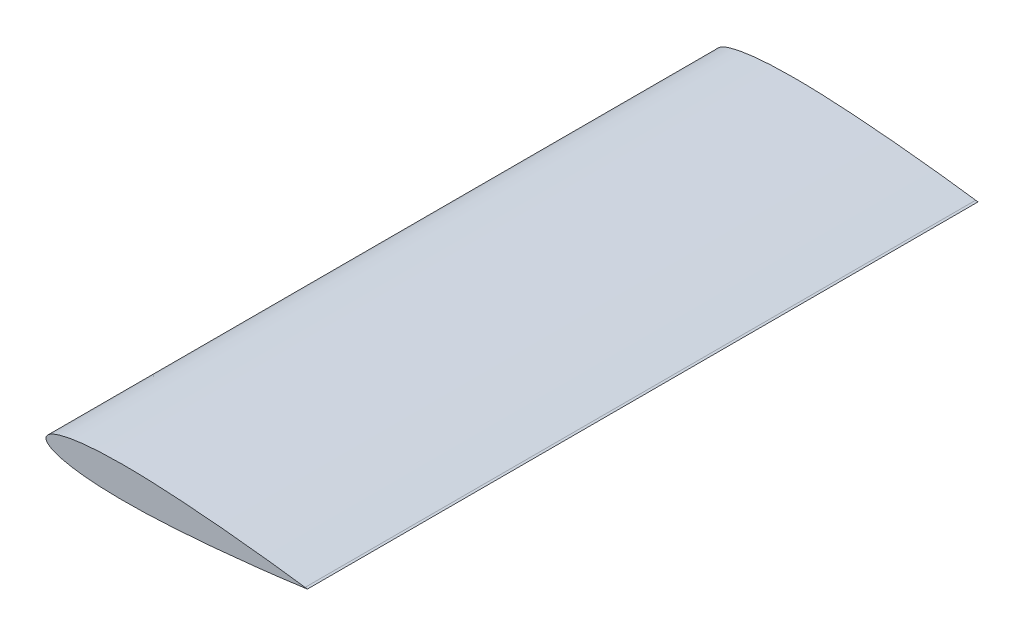
from build123d import *

# Parameters (mm, degrees)
BOSS_EXTRUDE1_DEPTH = 220


with BuildPart() as part:
    # Sketch1 → Boss-Extrude1 (new body, symmetric)
    with BuildSketch(Plane.XY):
        with BuildLine():
            Line((170, 0.2142), (171.526860264, 0))
            Line((171.526860264, 0), (170, -0.2142))
            add(Edge.make_bspline(
                [(170, 0.2142), (169.966912443, 0.218841783), (169.834644693, 0.237397347), (169.537331795, 0.279020665), (169.042585832, 0.348135674), (168.351558182, 0.444216313), (167.465863607, 0.566673358), (166.387572959, 0.714703343), (165.119198798, 0.887388895), (163.663704997, 1.083620123), (162.024491695, 1.302240346), (160.205384018, 1.541874109), (158.210635248, 1.801234189), (156.044891082, 2.078726966), (153.713220647, 2.372929467), (151.221064664, 2.68219487), (148.574250468, 3.004964361), (145.778948667, 3.339545929), (142.841695728, 3.68429103), (139.769352063, 4.037505882), (136.569099282, 4.397547939), (133.248399008, 4.762587708), (128.603273013, 5.261008627), (123.823466764, 5.75403377), (118.920129266, 6.238359408), (115.118534428, 6.602078324), (111.246602437, 6.959989686), (107.31336672, 7.310084978), (103.328024817, 7.650351054), (99.299869798, 7.978725616), (95.238315945, 8.293063594), (91.152846311, 8.591261597), (87.053003855, 8.871084403), (82.948358769, 9.130334997), (78.848496902, 9.366808942), (74.762991866, 9.57830934), (70.701378826, 9.762705464), (66.673140242, 9.917904381), (62.687685268, 10.041909396), (58.75432258, 10.132909314), (54.882228231, 10.189174322), (51.080443438, 10.209179867), (47.357845079, 10.191617694), (43.723127646, 10.135437631), (40.184771238, 10.039769994), (36.751033364, 9.904092016), (33.429930956, 9.728150057), (30.229218361, 9.511904807), (27.156351985, 9.255719335), (24.218491951, 8.960186235), (21.42248875, 8.626127825), (18.774840358, 8.254737362), (16.281705052, 7.84726864), (13.948836888, 7.405393904), (11.781628799, 6.930720867), (9.785012542, 6.425199486), (7.963520319, 5.890664946), (6.321160915, 5.329131112), (4.861439729, 4.742479239), (3.587252676, 4.132455505), (2.500858912, 3.500442704), (1.603848389, 2.847158922), (0.897527199, 2.171979974), (0.384180689, 1.472534355), (0.070040458, 0.745786292), (-0.034142784, 0), (0.070040458, -0.745786292), (0.384180689, -1.472534355), (0.897527199, -2.171979974), (1.603848389, -2.847158922), (2.500858912, -3.500442704), (3.587252676, -4.132455505), (4.861439729, -4.742479239), (6.321160915, -5.329131112), (7.963520319, -5.890664946), (9.785012542, -6.425199486), (11.781628799, -6.930720867), (13.948836888, -7.405393904), (16.281705052, -7.84726864), (18.774840358, -8.254737362), (21.42248875, -8.626127825), (24.218491951, -8.960186235), (27.156351985, -9.255719335), (30.229218361, -9.511904807), (33.429930956, -9.728150057), (36.751033364, -9.904092016), (40.184771238, -10.039769994), (43.723127646, -10.135437631), (47.357845079, -10.191617694), (51.080443438, -10.209179867), (54.882228231, -10.189174322), (58.75432258, -10.132909314), (62.687685268, -10.041909396), (66.673140242, -9.917904381), (70.701378826, -9.762705464), (74.762991866, -9.57830934), (78.848496902, -9.366808942), (82.948358769, -9.130334997), (87.053003855, -8.871084403), (91.152846311, -8.591261597), (95.238315945, -8.293063594), (99.299869798, -7.978725616), (103.328024817, -7.650351054), (107.31336672, -7.310084978), (111.246602437, -6.959989686), (116.361045787, -6.487223793), (122.556207078, -5.88475081), (128.603273013, -5.261008627), (133.248399008, -4.762587708), (136.569099282, -4.397547939), (139.769352063, -4.037505882), (142.841695728, -3.68429103), (145.778948667, -3.339545929), (148.574250468, -3.004964361), (151.221064664, -2.68219487), (153.713220647, -2.372929467), (156.044891082, -2.078726966), (158.210635248, -1.801234189), (160.205384018, -1.541874109), (162.024491695, -1.302240346), (163.663704997, -1.083620123), (165.119198798, -0.887388895), (166.387572959, -0.714703343), (167.465863607, -0.566673358), (168.351558182, -0.444216313), (169.042585832, -0.348135674), (169.537331795, -0.279020665), (169.834644693, -0.237397347), (169.966912443, -0.218841783), (170, -0.2142)],
                knots=[0, 0, 0, 0, 0.000289146, 0.001155863, 0.002598059, 0.004612289, 0.007193593, 0.010335835, 0.014031413, 0.018271453, 0.023045738, 0.028342882, 0.034150137, 0.040453731, 0.047238593, 0.054488555, 0.062186438, 0.070313976, 0.078851943, 0.087780092, 0.097077362, 0.106721847, 0.116690748, 0.137507311, 0.148305913, 0.15933101, 0.170556758, 0.181956676, 0.19350401, 0.205171586, 0.216932159, 0.228757987, 0.24062146, 0.252494886, 0.264350491, 0.276160731, 0.287898257, 0.299535925, 0.311046959, 0.322405016, 0.333584241, 0.344559427, 0.355305877, 0.365799652, 0.376017633, 0.385937515, 0.395537821, 0.404798054, 0.413698797, 0.422221689, 0.430349461, 0.438066152, 0.445357166, 0.452209423, 0.458611485, 0.464554009, 0.470029938, 0.475035084, 0.479569179, 0.483636916, 0.487250222, 0.490431493, 0.493218847, 0.49567407, 0.497891229, 0.5, 0.502108771, 0.50432593, 0.506781153, 0.509568507, 0.512749778, 0.516363084, 0.520430821, 0.524964916, 0.529970062, 0.535445991, 0.541388515, 0.547790577, 0.554642834, 0.561933848, 0.569650539, 0.577778311, 0.586301203, 0.595201946, 0.604462179, 0.614062485, 0.623982367, 0.634200348, 0.644694123, 0.655440573, 0.666415759, 0.677594984, 0.688953041, 0.700464075, 0.712101743, 0.723839269, 0.735649509, 0.747505114, 0.75937854, 0.771242013, 0.783067841, 0.794828414, 0.80649599, 0.818043324, 0.829443242, 0.84066899, 0.862492689, 0.883309252, 0.893278153, 0.902922638, 0.912219908, 0.921148057, 0.929686024, 0.937813562, 0.945511445, 0.952761407, 0.959546269, 0.965849863, 0.971657118, 0.976954262, 0.981728547, 0.985968587, 0.989664165, 0.992806407, 0.995387711, 0.997401941, 0.998844137, 0.999710854, 1, 1, 1, 1], degree=3))
        make_face()
    extrude(amount=BOSS_EXTRUDE1_DEPTH, both=True)


solid = part.part
